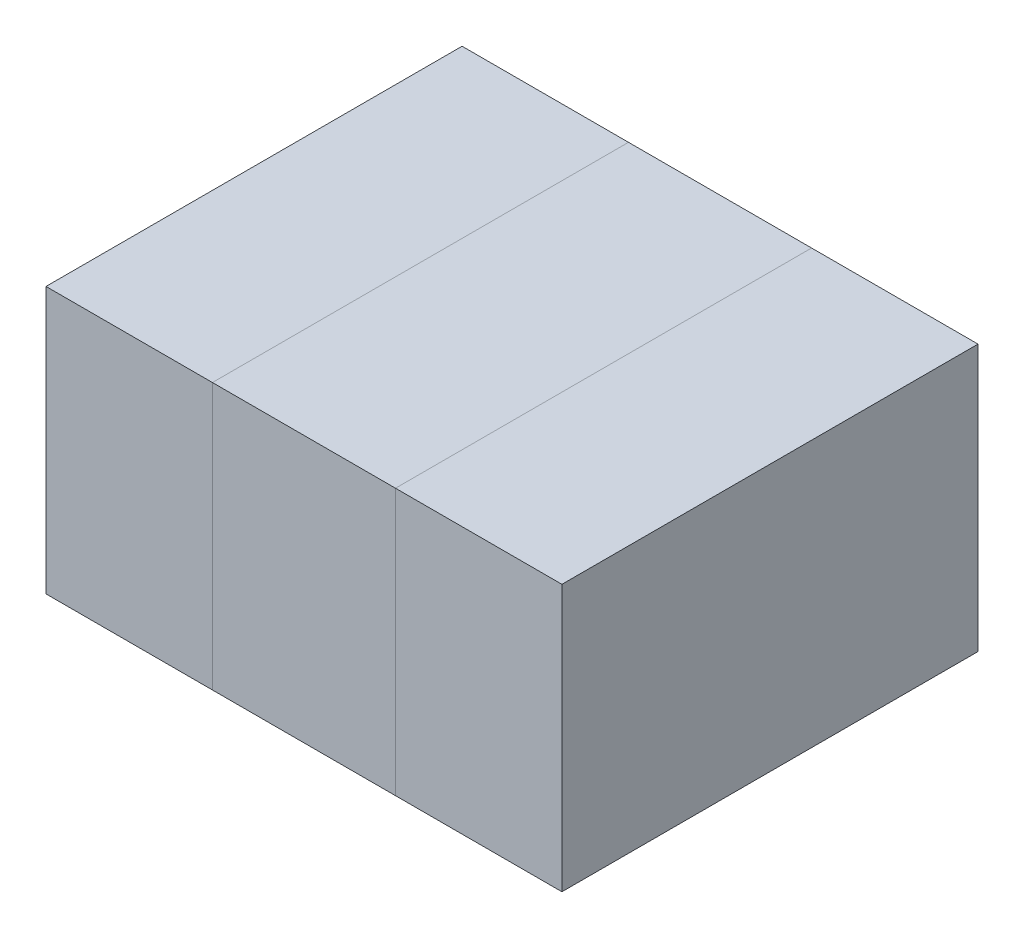
from build123d import *

# Parameters (mm, degrees)
SKETCH1_W             = 0.55
SKETCH1_H             = 1.25
BOSS_EXTRUDE1_DEPTH   = 0.8
SKETCH2_W             = 0.5
SKETCH2_H             = 1.25
BOSS_EXTRUDE2_DEPTH   = 0.8
BOSS_EXTRUDE2_2_DEPTH = 0.8


with BuildPart() as part:
    # Sketch1 → Boss-Extrude1 (new body)
    with BuildSketch(Plane(origin=(0, 0, 0), x_dir=(1, 0, 0), z_dir=(0, 1, 0))):
        Rectangle(SKETCH1_W, SKETCH1_H)
    extrude(amount=BOSS_EXTRUDE1_DEPTH)


with BuildPart() as body_2:
    # Sketch2 → Boss-Extrude2 (new body)
    with BuildSketch(Plane(origin=(0, 0, 0), x_dir=(1, 0, 0), z_dir=(0, 1, 0))):
        with Locations((-0.525, 0)):
            Rectangle(SKETCH2_W, SKETCH2_H)
    extrude(amount=BOSS_EXTRUDE2_DEPTH)


with BuildPart() as body_3:
    # Sketch2 → Boss-Extrude2 2 (new body)
    with BuildSketch(Plane(origin=(0, 0, 0), x_dir=(1, 0, 0), z_dir=(0, 1, 0))):
        with Locations((0.525, 0)):
            Rectangle(SKETCH2_W, SKETCH2_H)
    extrude(amount=BOSS_EXTRUDE2_2_DEPTH)


solid = Compound([part.part, body_2.part, body_3.part])
